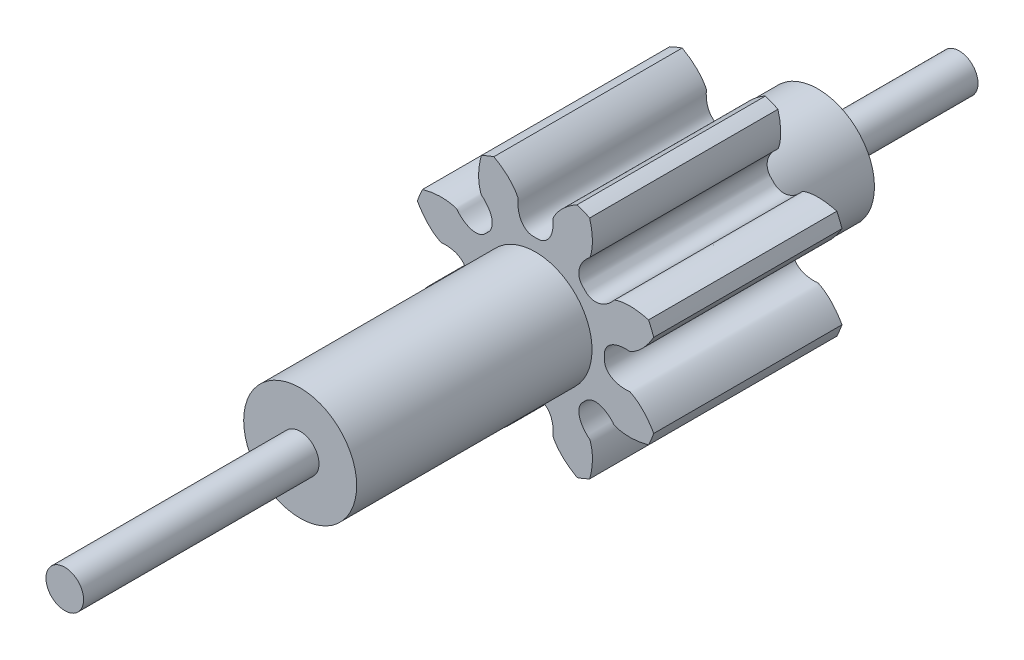
from build123d import *

# Parameters (mm, degrees)
SKETCHREVOLVEENGRANAJE_8D_W       = 1
SKETCHREVOLVEENGRANAJE_8D_H       = 0.665384615
TOOTHEXTRUDECUTENGRANAJE_8D_DEPTH = 0.75
PATTERNENGRANAJE_8D_COUNT         = 8
CROQUIS5_R                        = 0.3
SALIENTE_EXTRUIR1_DEPTH           = 1.25
CROQUIS6_R                        = 0.1
SALIENTE_EXTRUIR2_DEPTH           = 1.25
SALIENTE_EXTRUIR3_START           = 0.5
CROQUIS7_R                        = 0.3
SALIENTE_EXTRUIR3_DEPTH           = 0.5
SALIENTE_EXTRUIR4_START           = 0.75
CROQUIS8_R                        = 0.1
SALIENTE_EXTRUIR4_DEPTH           = 0.75


with BuildPart() as part:
    # SketchRevolveEngranaje 8d → Engranaje 8d (revolve)
    with BuildSketch(Plane(origin=(0, 0, 0), x_dir=(0, 0, -1), z_dir=(1, 0, 0))):
        with Locations((-0.25, 0.332692308)):
            Rectangle(SKETCHREVOLVEENGRANAJE_8D_W, SKETCHREVOLVEENGRANAJE_8D_H)
    revolve(axis=Axis((0, 0, 0), (0, 0, -1)))

    # SketchToothEngranaje 8d → ToothExtrudeCutEngranaje 8d (cut, symmetric)
    with BuildSketch(Plane.XY):
        with BuildLine():
            ThreePointArc((0.627610393, 0.221001993), (0.665384615, 0), (0.627610393, -0.221001993))
            add(Edge.make_bspline(
                [(0.627610393, -0.221001993), (0.621637211, -0.210378136), (0.612267603, -0.195220178), (0.598823858, -0.176435393), (0.58902438, -0.163938234), (0.579313406, -0.152612959), (0.569773641, -0.142426417), (0.560485007, -0.13334037), (0.551524311, -0.125312193), (0.542965157, -0.118293482), (0.534877127, -0.112235484), (0.527327398, -0.107072342), (0.520374573, -0.102775796), (0.51408721, -0.099183749), (0.50709896, -0.095873313), (0.49856174, -0.090789328), (0.488829901, -0.093525946), (0.480638724, -0.093453045), (0.474412036, -0.093494521), (0.468311645, -0.09326513), (0.462326945, -0.092863413), (0.456463592, -0.092265781), (0.450722799, -0.091480006), (0.445106766, -0.090505096), (0.439617312, -0.089341668), (0.434256309, -0.087989129), (0.429025663, -0.086446292), (0.423927453, -0.084711087), (0.418964066, -0.082780506), (0.4141384, -0.080650493), (0.409454099, -0.078315865), (0.404915875, -0.075770259), (0.400529895, -0.073006137), (0.396304249, -0.070014872), (0.392249501, -0.066786969), (0.38837931, -0.063312458), (0.384711075, -0.059581534), (0.381266544, -0.055585486), (0.378072274, -0.05131798), (0.375159824, -0.046776686), (0.372565336, -0.0419652), (0.37032892, -0.036895063), (0.368491391, -0.031587703), (0.3670971, -0.026075488), (0.366169697, -0.020403027), (0.365836187, -0.015355699), (0.365746097, -0.008547234), (0.366123675, 0), (0.365746097, 0.008547234), (0.365836187, 0.015355699), (0.366169697, 0.020403027), (0.3670971, 0.026075488), (0.368491391, 0.031587703), (0.37032892, 0.036895063), (0.372565336, 0.0419652), (0.375159824, 0.046776686), (0.378072274, 0.05131798), (0.381266544, 0.055585486), (0.384711075, 0.059581534), (0.38837931, 0.063312458), (0.392249501, 0.066786969), (0.396304249, 0.070014872), (0.400529895, 0.073006137), (0.404915875, 0.075770259), (0.409454099, 0.078315865), (0.4141384, 0.080650493), (0.418964066, 0.082780506), (0.423927453, 0.084711087), (0.429025663, 0.086446292), (0.434256309, 0.087989129), (0.439617312, 0.089341668), (0.445106766, 0.090505096), (0.450722799, 0.091480006), (0.456463592, 0.092265781), (0.462326945, 0.092863413), (0.468311645, 0.09326513), (0.474412036, 0.093494521), (0.480638724, 0.093453045), (0.488829901, 0.093525946), (0.49856174, 0.090789328), (0.50709896, 0.095873313), (0.51408721, 0.099183749), (0.520374573, 0.102775796), (0.527327398, 0.107072342), (0.534877127, 0.112235484), (0.542965157, 0.118293482), (0.551524311, 0.125312193), (0.560485007, 0.13334037), (0.569773641, 0.142426417), (0.579313406, 0.152612959), (0.58902438, 0.163938234), (0.598823858, 0.176435393), (0.612267603, 0.195220178), (0.621637211, 0.210378136), (0.627610393, 0.221001993)],
                knots=[0, 0, 0, 0, 0.049065405, 0.071661316, 0.092966031, 0.112979552, 0.131701878, 0.149133009, 0.165272945, 0.180121687, 0.193679233, 0.205945585, 0.216920742, 0.226604705, 0.234997473, 0.248332855, 0.264642337, 0.273139818, 0.281481765, 0.289672885, 0.297718345, 0.305623829, 0.313395584, 0.321040486, 0.328566105, 0.335980768, 0.343293633, 0.350514757, 0.357655161, 0.364726886, 0.37174303, 0.378717761, 0.385666276, 0.39260471, 0.399549953, 0.406519354, 0.413530284, 0.42059954, 0.427742558, 0.434972464, 0.442299001, 0.44972742, 0.457257496, 0.464882862, 0.472590865, 0.480363101, 0.485221717, 0.5, 0.514778283, 0.519636899, 0.527409135, 0.535117138, 0.542742504, 0.55027258, 0.557700999, 0.565027536, 0.572257442, 0.57940046, 0.586469716, 0.593480646, 0.600450047, 0.60739529, 0.614333724, 0.621282239, 0.62825697, 0.635273114, 0.642344839, 0.649485243, 0.656706367, 0.664019232, 0.671433895, 0.678959514, 0.686604416, 0.694376171, 0.702281655, 0.710327115, 0.718518235, 0.726860182, 0.735357663, 0.751667145, 0.765002527, 0.773395295, 0.783079258, 0.794054415, 0.806320767, 0.819878313, 0.834727055, 0.850866991, 0.868298122, 0.887020448, 0.907033969, 0.928338684, 0.950934595, 1, 1, 1, 1], degree=3))
        make_face()
    toothextrudecutengranaje_8d = extrude(amount=TOOTHEXTRUDECUTENGRANAJE_8D_DEPTH, both=True, mode=Mode.SUBTRACT)

    # PatternEngranaje 8d: ToothExtrudeCutEngranaje 8d ×8 about axis
    patternengranaje_8d_axis = Axis((0, 0, 55), (0, 0, -1))
    for i in range(1, PATTERNENGRANAJE_8D_COUNT):
        add(toothextrudecutengranaje_8d.rotate(patternengranaje_8d_axis, i * 360 / PATTERNENGRANAJE_8D_COUNT), mode=Mode.SUBTRACT)

    # Croquis5 → Saliente-Extruir1 (add)
    with BuildSketch(Plane.XY.offset(0.75)):
        Circle(CROQUIS5_R)
    extrude(amount=SALIENTE_EXTRUIR1_DEPTH)

    # Croquis6 → Saliente-Extruir2 (add)
    with BuildSketch(Plane.XY.offset(2)):
        Circle(CROQUIS6_R)
    extrude(amount=SALIENTE_EXTRUIR2_DEPTH)

    # Croquis7 → Saliente-Extruir3 (add)
    with BuildSketch(Plane(origin=(0, 0, -0.25), x_dir=(-1, 0, 0), z_dir=(0, 0, -1)).offset(SALIENTE_EXTRUIR3_START)):
        Circle(CROQUIS7_R)
    extrude(amount=-SALIENTE_EXTRUIR3_DEPTH)

    # Croquis8 → Saliente-Extruir4 (add)
    with BuildSketch(Plane(origin=(0, 0, -0.75), x_dir=(-1, 0, 0), z_dir=(0, 0, -1)).offset(SALIENTE_EXTRUIR4_START)):
        Circle(CROQUIS8_R)
    extrude(amount=-SALIENTE_EXTRUIR4_DEPTH)


solid = part.part
